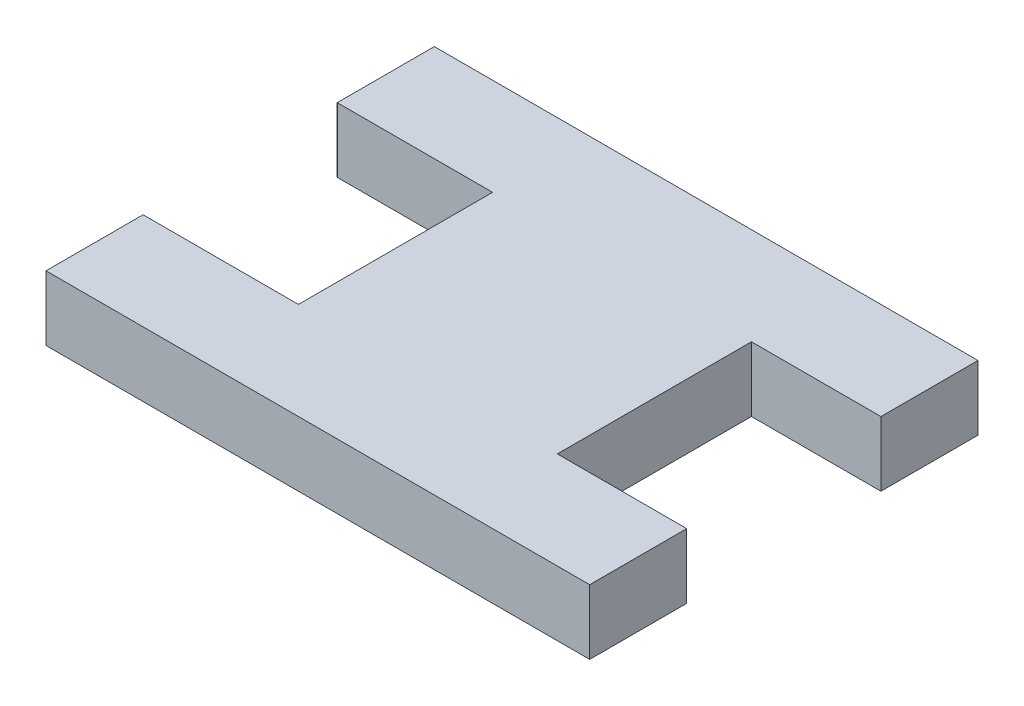
from build123d import *

# Parameters (mm, degrees)
SKETCH1_W           = 95
SKETCH1_H           = 30
SKETCH1_R           = 7
SKETCH1_R_2         = 1
BOSS_EXTRUDE1_DEPTH = 5
SKETCH3_W           = 5
SKETCH3_H           = 10
CUT_EXTRUDE2_DEPTH  = 10
SKETCH4_R           = 7
SKETCH4_R_2         = 1
CUT_EXTRUDE3_DEPTH  = 10
FILLET1_R           = 10
CUT_EXTRUDE4_REACH  = 7
SKETCH5_R           = 2.05
BOSS_EXTRUDE2_DEPTH = 5
CUT_EXTRUDE5_DEPTH  = 5


with BuildPart() as part:
    # Sketch1 → Boss-Extrude1 (new body)
    with BuildSketch(Plane(origin=(0, 0, 0), x_dir=(1, 0, 0), z_dir=(0, 1, 0))):
        Rectangle(SKETCH1_W, SKETCH1_H)
        with Locations((-32.5, 0)):
            Circle(SKETCH1_R, mode=Mode.SUBTRACT)
        with Locations((-42.9, 0)):
            Circle(SKETCH1_R_2, mode=Mode.SUBTRACT)
        with Locations((-45.9, 0)):
            Circle(SKETCH1_R_2, mode=Mode.SUBTRACT)
        with Locations((-32.5, 10.4)):
            Circle(SKETCH1_R_2, mode=Mode.SUBTRACT)
        with Locations((-32.5, 13.4)):
            Circle(SKETCH1_R_2, mode=Mode.SUBTRACT)
        with Locations((-22.1, 0)):
            Circle(SKETCH1_R_2, mode=Mode.SUBTRACT)
        with Locations((-19.1, 0)):
            Circle(SKETCH1_R_2, mode=Mode.SUBTRACT)
        with Locations((-32.5, -10.4)):
            Circle(SKETCH1_R_2, mode=Mode.SUBTRACT)
        with Locations((-32.5, -13.4)):
            Circle(SKETCH1_R_2, mode=Mode.SUBTRACT)
    extrude(amount=BOSS_EXTRUDE1_DEPTH)

    # Sketch3 → Cut-Extrude2 (cut)
    with BuildSketch(Plane(origin=(0, 5, 0), x_dir=(1, 0, 0), z_dir=(0, 1, 0))):
        with Locations((-5, 0)):
            Rectangle(SKETCH3_W, SKETCH3_H)
    extrude(amount=-CUT_EXTRUDE2_DEPTH, mode=Mode.SUBTRACT)

    # Sketch4 → Cut-Extrude3 (cut)
    with BuildSketch(Plane(origin=(0, 5, 0), x_dir=(1, 0, 0), z_dir=(0, 1, 0))):
        with Locations((-32.5, 0)):
            Circle(SKETCH4_R)
        with Locations((-32.5, -13.4)):
            Circle(SKETCH4_R_2)
        with Locations((-32.5, -10.4)):
            Circle(SKETCH4_R_2)
        with Locations((-42.9, 0)):
            Circle(SKETCH4_R_2)
        with Locations((-45.9, 0)):
            Circle(SKETCH4_R_2)
        with Locations((-32.5, 13.4)):
            Circle(SKETCH4_R_2)
        with Locations((-22.1, 0)):
            Circle(SKETCH4_R_2)
        with Locations((-19.1, 0)):
            Circle(SKETCH4_R_2)
        with Locations((-32.5, 10.4)):
            Circle(SKETCH4_R_2)
        with Locations((27.5, -13.4)):
            Circle(SKETCH4_R_2)
        with Locations((27.5, -10.4)):
            Circle(SKETCH4_R_2)
        with Locations((40.9, 0)):
            Circle(SKETCH4_R_2)
        with Locations((37.9, 0)):
            Circle(SKETCH4_R_2)
        with Locations((27.5, 0)):
            Circle(SKETCH4_R)
        with Locations((27.5, 10.4)):
            Circle(SKETCH4_R_2)
        with Locations((27.5, 13.4)):
            Circle(SKETCH4_R_2)
        with Locations((17.1, 0)):
            Circle(SKETCH4_R_2)
        with Locations((14.1, 0)):
            Circle(SKETCH4_R_2)
    extrude(amount=-CUT_EXTRUDE3_DEPTH, mode=Mode.SUBTRACT)

    # Fillet1
    fillet1_edges = [part.edges().sort_by_distance(p)[0] for p in [
        (47.5, 2.5, 15),
        (-47.5, 2.5, 15),
        (-47.5, 2.5, -15),
        (47.5, 2.5, -15),
    ]]
    fillet(fillet1_edges, radius=FILLET1_R)

    # Sketch5 → Cut-Extrude4 (cut, up to next)
    with BuildSketch(Plane(origin=(0, 5, 0), x_dir=(1, 0, 0), z_dir=(0, 1, 0)), mode=Mode.PRIVATE) as cut_extrude4_sk1:
        with Locations((-7.5, 5)):
            Circle(SKETCH5_R)
    cut_extrude4_tool1 = extrude(cut_extrude4_sk1.sketch, amount=-CUT_EXTRUDE4_REACH, mode=Mode.PRIVATE) & part.part
    add(cut_extrude4_tool1.solids().sort_by_distance((-7.5, 5, -5))[0], mode=Mode.SUBTRACT)
    # Sketch5 → Cut-Extrude4 (cut, up to next)
    with BuildSketch(Plane(origin=(0, 5, 0), x_dir=(1, 0, 0), z_dir=(0, 1, 0)), mode=Mode.PRIVATE) as cut_extrude4_sk2:
        with Locations((-2.5, 5)):
            Circle(SKETCH5_R)
    cut_extrude4_tool2 = extrude(cut_extrude4_sk2.sketch, amount=-CUT_EXTRUDE4_REACH, mode=Mode.PRIVATE) & part.part
    add(cut_extrude4_tool2.solids().sort_by_distance((-2.5, 5, -5))[0], mode=Mode.SUBTRACT)
    # Sketch5 → Cut-Extrude4 (cut, up to next)
    with BuildSketch(Plane(origin=(0, 5, 0), x_dir=(1, 0, 0), z_dir=(0, 1, 0)), mode=Mode.PRIVATE) as cut_extrude4_sk3:
        with Locations((-2.5, -5)):
            Circle(SKETCH5_R)
    cut_extrude4_tool3 = extrude(cut_extrude4_sk3.sketch, amount=-CUT_EXTRUDE4_REACH, mode=Mode.PRIVATE) & part.part
    add(cut_extrude4_tool3.solids().sort_by_distance((-2.5, 5, 5))[0], mode=Mode.SUBTRACT)
    # Sketch5 → Cut-Extrude4 (cut, up to next)
    with BuildSketch(Plane(origin=(0, 5, 0), x_dir=(1, 0, 0), z_dir=(0, 1, 0)), mode=Mode.PRIVATE) as cut_extrude4_sk4:
        with Locations((-7.5, -5)):
            Circle(SKETCH5_R)
    cut_extrude4_tool4 = extrude(cut_extrude4_sk4.sketch, amount=-CUT_EXTRUDE4_REACH, mode=Mode.PRIVATE) & part.part
    add(cut_extrude4_tool4.solids().sort_by_distance((-7.5, 5, 5))[0], mode=Mode.SUBTRACT)

    # Sketch6 → Boss-Extrude2 (add)
    with BuildSketch(Plane(origin=(0, 5, 0), x_dir=(1, 0, 0), z_dir=(0, 1, 0))):
        Polygon((-22.5, 15), (19.5, 15), (19.5, 7.5), (9.5, 7.5), (9.5, -7.5), (19.5, -7.5), (19.5, -15), (-22.5, -15), (-22.5, -7.5), (-10.5, -7.5), (-10.5, 7.5), (-22.5, 7.5), align=None)
    extrude(amount=BOSS_EXTRUDE2_DEPTH)

    # Sketch8 → Cut-Extrude5 (cut)
    with BuildSketch(Plane.XZ):
        with BuildLine():
            Line((47.5, -5), (47.5, 5))
            ThreePointArc((47.5, 5), (44.571067812, 12.071067812), (37.5, 15))
            Line((37.5, 15), (-37.5, 15))
            ThreePointArc((-37.5, 15), (-44.571067812, 12.071067812), (-47.5, 5))
            Line((-47.5, 5), (-47.5, -5))
            ThreePointArc((-47.5, -5), (-44.571067812, -12.071067812), (-37.5, -15))
            Line((-37.5, -15), (37.5, -15))
            ThreePointArc((37.5, -15), (44.571067812, -12.071067812), (47.5, -5))
        make_face()
    extrude(amount=-CUT_EXTRUDE5_DEPTH, mode=Mode.SUBTRACT)


solid = part.part
